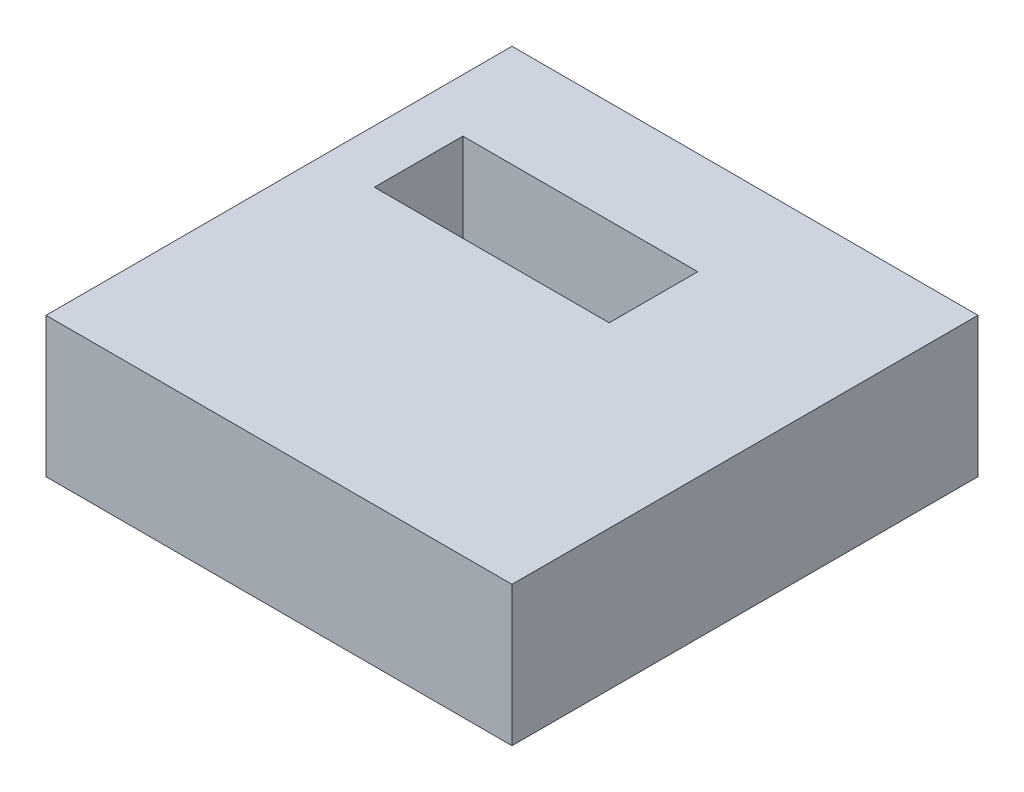
from build123d import *

# Parameters (mm, degrees)
SKETCH1_W           = 100
SKETCH1_H           = 100
SKETCH1_W_2         = 50.4
SKETCH1_H_2         = 19
BOSS_EXTRUDE1_DEPTH = 30


with BuildPart() as part:
    # Sketch1 → Boss-Extrude1 (new body)
    with BuildSketch(Plane(origin=(0, 0, 0), x_dir=(1, 0, 0), z_dir=(0, 1, 0))):
        Rectangle(SKETCH1_W, SKETCH1_H)
        with Locations((-13.37, 18.53)):
            Rectangle(SKETCH1_W_2, SKETCH1_H_2, mode=Mode.SUBTRACT)
    extrude(amount=BOSS_EXTRUDE1_DEPTH)


solid = part.part
